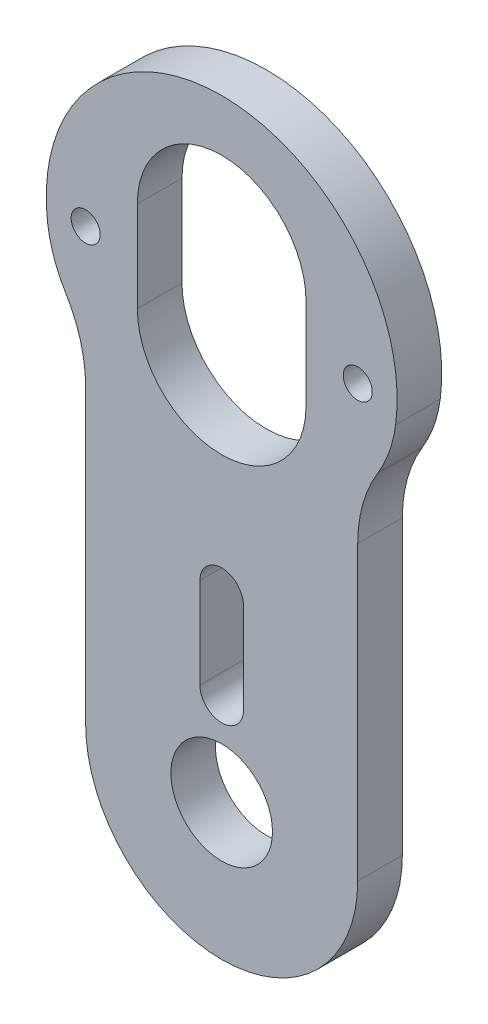
from build123d import *

# Parameters (mm, degrees)
CROQUIS1_R              = 3.556
SALIENTE_EXTRUIR1_DEPTH = 3.1242
SALIENTE_EXTRUIR3_START = -3.1242
SALIENTE_EXTRUIR3_DEPTH = 3.1242
CROQUIS3_R              = 1.016
CORTAR_EXTRUIR1_DEPTH   = 45.69699718


with BuildPart() as part:
    # Croquis1 → Saliente-Extruir1 (new body)
    with BuildSketch(Plane.XY):
        with BuildLine():
            Line((9.525, 0), (9.525, 33.3375))
            ThreePointArc((9.525, 33.3375), (0, 42.8625), (-9.525, 33.3375))
            Line((-9.525, 33.3375), (-9.525, 0))
            ThreePointArc((-9.525, 0), (0, -9.525), (9.525, 0))
        make_face()
        Circle(CROQUIS1_R, mode=Mode.SUBTRACT)
        with BuildLine():
            ThreePointArc((-5.9055, 26.9875), (0, 21.082), (5.9055, 26.9875))
            Line((5.9055, 26.9875), (5.9055, 33.3375))
            ThreePointArc((5.9055, 33.3375), (0, 39.243), (-5.9055, 33.3375))
            Line((-5.9055, 33.3375), (-5.9055, 26.9875))
        make_face(mode=Mode.SUBTRACT)
        with BuildLine():
            ThreePointArc((1.524, 12.7), (0, 14.224), (-1.524, 12.7))
            Line((-1.524, 12.7), (-1.524, 6.35))
            ThreePointArc((-1.524, 6.35), (0, 4.826), (1.524, 6.35))
            Line((1.524, 6.35), (1.524, 12.7))
        make_face(mode=Mode.SUBTRACT)
    extrude(amount=SALIENTE_EXTRUIR1_DEPTH)

    # Croquis2 → Saliente-Extruir3 (add)
    with BuildSketch(Plane.XY.offset(3.1242).offset(SALIENTE_EXTRUIR3_START)):
        with BuildLine():
            ThreePointArc((-9.525, 33.3375), (-6.735192091, 40.072692091), (0, 42.8625))
            ThreePointArc((0, 42.8625), (-9.233702216, 38.679444926), (-12.178104888, 28.979460428))
            ThreePointArc((-12.178104888, 28.979460428), (-11.736773179, 27.137352023), (-10.922866894, 25.426886118))
            ThreePointArc((-10.922866894, 25.426886118), (-9.881124174, 23.039641343), (-9.525, 20.459458969))
            Line((-9.525, 20.459458969), (-9.525, 29.1465))
            ThreePointArc((-9.525, 29.1465), (-10.541, 30.1625), (-9.525, 31.1785))
            Line((-9.525, 31.1785), (-9.525, 33.3375))
        make_face()
        with BuildLine():
            ThreePointArc((12.178104888, 28.979460428), (9.233702216, 38.679444926), (0, 42.8625))
            ThreePointArc((0, 42.8625), (6.735192091, 40.072692091), (9.525, 33.3375))
            Line((9.525, 33.3375), (9.525, 31.1785))
            ThreePointArc((9.525, 31.1785), (10.541, 30.1625), (9.525, 29.1465))
            Line((9.525, 29.1465), (9.525, 20.459458969))
            ThreePointArc((9.525, 20.459458969), (9.881124174, 23.039641343), (10.922866894, 25.426886118))
            ThreePointArc((10.922866894, 25.426886118), (11.736773179, 27.137352023), (12.178104888, 28.979460428))
        make_face()
    extrude(amount=SALIENTE_EXTRUIR3_DEPTH)

    # Croquis3 → Cortar-Extruir1 (cut, through all)
    with BuildSketch(Plane.XY.offset(3.1242)):
        with Locations((-9.525, 30.1625)):
            Circle(CROQUIS3_R)
        with Locations((9.525, 30.1625)):
            Circle(CROQUIS3_R)
    extrude(amount=-CORTAR_EXTRUIR1_DEPTH, mode=Mode.SUBTRACT)


solid = part.part
